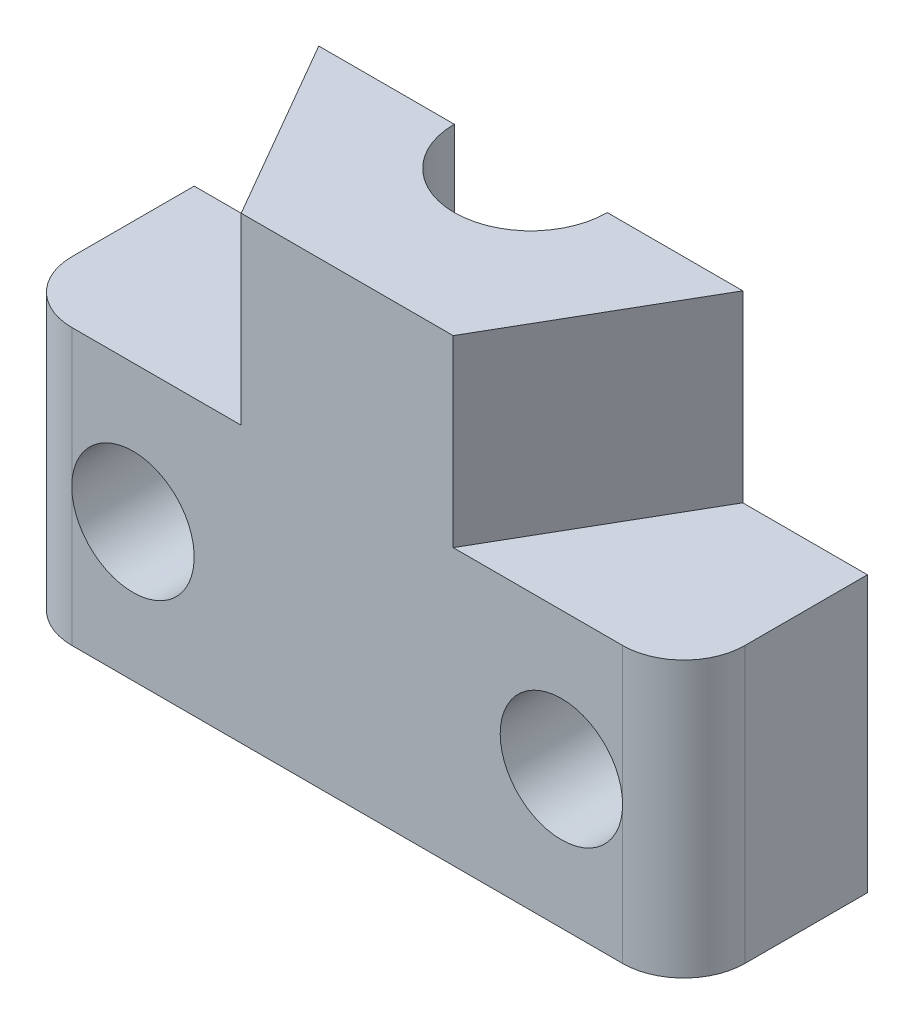
from build123d import *

# Parameters (mm, degrees)
SKETCH_1_W           = 22
SKETCH_1_H           = 12
EXTRUDE_1_DEPTH      = 9
FILLET_1_R           = 2
SKETCH_2_R           = 3.6
CUT_EXTRUDE_1_DEPTH  = 8
SKETCH_3_R           = 5
CUT_EXTRUDE_2_DEPTH  = 1
EXTRUDE_2_DEPTH      = 6
CUT_EXTRUDE_5_DEPTH  = 3
SKETCH_8_R           = 2.5
CUT_EXTRUDE_6_DEPTH  = 6
SKETCH_11_R          = 2
CUT_EXTRUDE_9_DEPTH  = 13
SKETCH_12_W          = 27.17111841
SKETCH_12_H          = 33.234136994
CUT_EXTRUDE_10_DEPTH = 10


with BuildPart() as part:
    # Эскиз1 → Бобышка-Вытянуть1 (new body)
    with BuildSketch(Plane(origin=(0, 0, 0), x_dir=(1, 0, 0), z_dir=(0, 1, 0))):
        Rectangle(SKETCH_1_W, SKETCH_1_H)
    extrude(amount=EXTRUDE_1_DEPTH)

    # Скругление1
    fillet_1_edges = [part.edges().sort_by_distance(p)[0] for p in [
        (11, 4.5, 6),
        (-11, 4.5, 6),
        (-11, 4.5, -6),
        (11, 4.5, -6),
    ]]
    fillet(fillet_1_edges, radius=FILLET_1_R)

    # Эскиз2 → Вырез-Вытянуть1 (cut)
    with BuildSketch(Plane(origin=(0, 0, 0), x_dir=(1, 0, 0), z_dir=(0, 1, 0))):
        Circle(SKETCH_2_R)
    extrude(amount=CUT_EXTRUDE_1_DEPTH, mode=Mode.SUBTRACT)

    # Эскиз3 → Вырез-Вытянуть2 (cut, symmetric)
    with BuildSketch(Plane.XZ.offset(-8)):
        Circle(SKETCH_3_R)
    extrude(amount=CUT_EXTRUDE_2_DEPTH, both=True, mode=Mode.SUBTRACT)

    # Эскиз6 → Бобышка-Вытянуть2 (add)
    with BuildSketch(Plane(origin=(0, 9, 0), x_dir=(1, 0, 0), z_dir=(0, 1, 0))):
        Polygon((6.92820323, 0), (3.464101615, 6), (-3.464101615, 6), (-6.92820323, 0), (-3.464101615, -6), (3.464101615, -6), align=None)
    extrude(amount=EXTRUDE_2_DEPTH)

    # Эскиз7 → Вырез-Вытянуть5 (cut)
    with BuildSketch(Plane(origin=(0, 9, 0), x_dir=(1, 0, 0), z_dir=(0, 1, 0))):
        Polygon((4.618802154, 0), (2.309401077, 4), (-2.309401077, 4), (-4.618802154, 0), (-2.309401077, -4), (2.309401077, -4), align=None)
    extrude(amount=CUT_EXTRUDE_5_DEPTH, mode=Mode.SUBTRACT)

    # Эскиз8 → Вырез-Вытянуть6 (cut)
    with BuildSketch(Plane(origin=(0, 9, 0), x_dir=(1, 0, 0), z_dir=(0, 1, 0))):
        Circle(SKETCH_8_R)
    extrude(amount=CUT_EXTRUDE_6_DEPTH, mode=Mode.SUBTRACT)

    # Эскиз11 → Вырез-Вытянуть9 (cut, through all)
    with BuildSketch(Plane(origin=(0, 0, -6), x_dir=(-1, 0, 0), z_dir=(0, 0, -1))):
        with Locations((7, 4.5)):
            Circle(SKETCH_11_R)
    cut_extrude_9 = extrude(amount=-CUT_EXTRUDE_9_DEPTH, mode=Mode.SUBTRACT)

    # Зеркальное отражение6: Вырез-Вытянуть9 across plane
    add(cut_extrude_9.mirror(Plane(origin=(0, 0, 0), x_dir=(0, 0, 1), z_dir=(1, 0, 0))), mode=Mode.SUBTRACT)

    # Эскиз12 → Вырез-Вытянуть10 (cut)
    with BuildSketch(Plane.XY):
        Rectangle(SKETCH_12_W, SKETCH_12_H)
    extrude(amount=-CUT_EXTRUDE_10_DEPTH, mode=Mode.SUBTRACT)


solid = part.part
